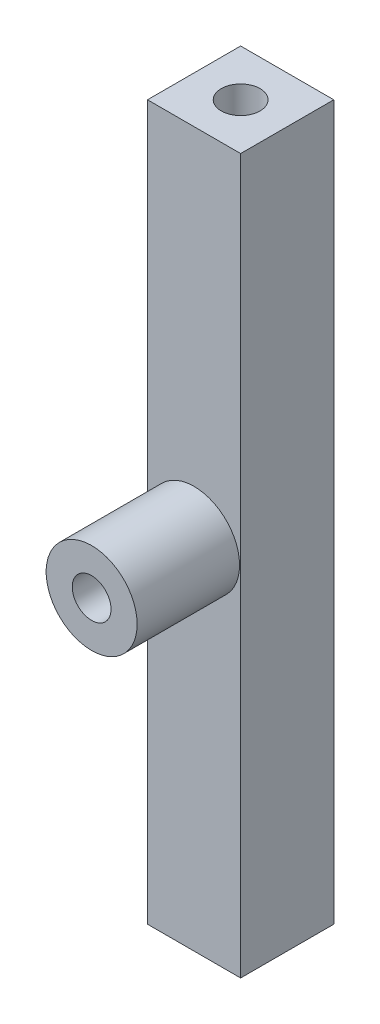
from build123d import *

# Parameters (mm, degrees)
SKETCH1_W           = 6
SKETCH1_H           = 46
BOSS_EXTRUDE1_DEPTH = 6
SKETCH2_R           = 1.25
CUT_EXTRUDE2_DEPTH  = 10
SKETCH3_R           = 1.25
CUT_EXTRUDE3_DEPTH  = 10
SKETCH4_R           = 2.93
BOSS_EXTRUDE2_DEPTH = 6.6
SKETCH5_R           = 1.25
CUT_EXTRUDE4_DEPTH  = 7


with BuildPart() as part:
    # Sketch1 → Boss-Extrude1 (new body)
    with BuildSketch(Plane.XY):
        Rectangle(SKETCH1_W, SKETCH1_H)
    extrude(amount=BOSS_EXTRUDE1_DEPTH)

    # Sketch2 → Cut-Extrude2 (cut)
    with BuildSketch(Plane(origin=(0, 23, 0), x_dir=(1, 0, 0), z_dir=(0, 1, 0))):
        with Locations((0, -3)):
            Circle(SKETCH2_R)
    extrude(amount=-CUT_EXTRUDE2_DEPTH, mode=Mode.SUBTRACT)

    # Sketch3 → Cut-Extrude3 (cut)
    with BuildSketch(Plane.XZ.offset(23)):
        with Locations((0, 3)):
            Circle(SKETCH3_R)
    extrude(amount=-CUT_EXTRUDE3_DEPTH, mode=Mode.SUBTRACT)

    # Sketch4 → Boss-Extrude2 (add)
    with BuildSketch(Plane.XY.offset(6)):
        Circle(SKETCH4_R)
    extrude(amount=BOSS_EXTRUDE2_DEPTH)

    # Sketch5 → Cut-Extrude4 (cut)
    with BuildSketch(Plane.XY.offset(12.6)):
        Circle(SKETCH5_R)
    extrude(amount=-CUT_EXTRUDE4_DEPTH, mode=Mode.SUBTRACT)


solid = part.part
